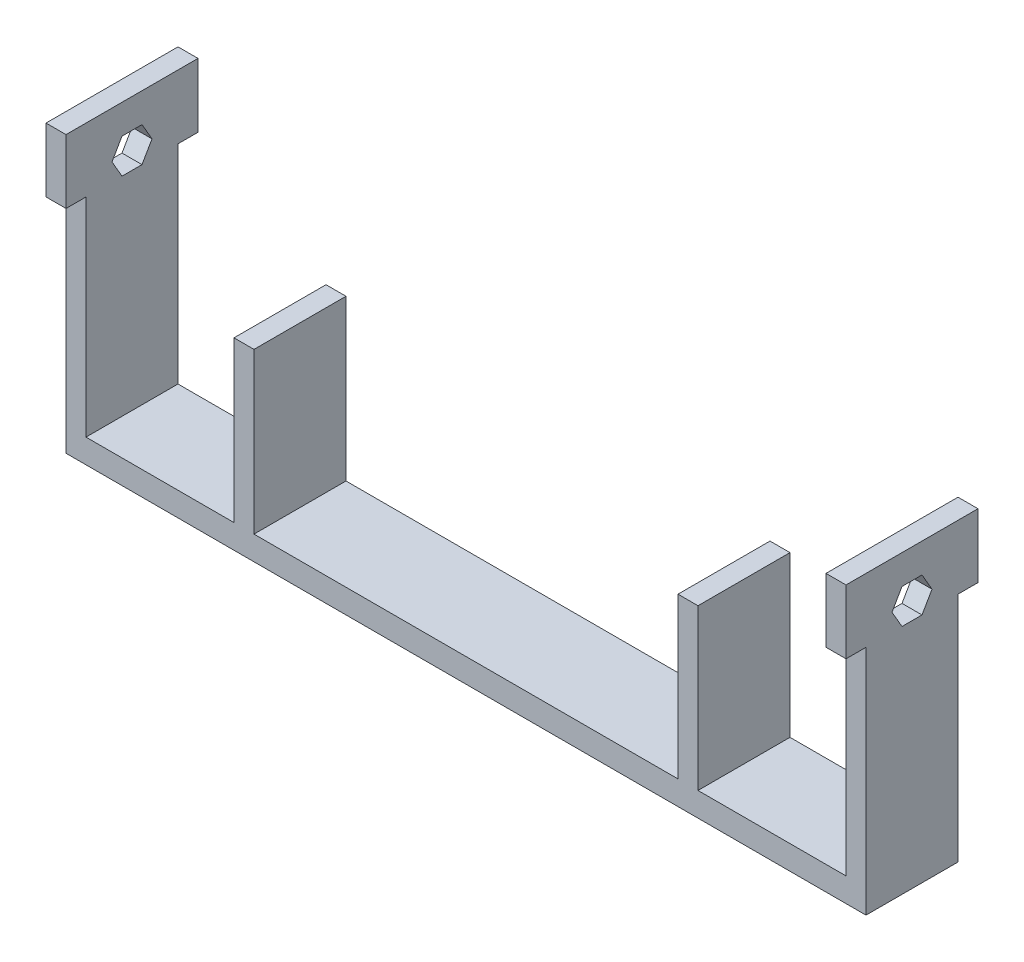
from build123d import *

# Parameters (mm, degrees)
SKETCH_1_W          = 100
SKETCH_1_H          = 11.5
EXTRUDE_1_DEPTH     = 3
SKETCH_2_W          = 2.5
SKETCH_2_H          = 11.5
EXTRUDE_2_DEPTH     = 26
SKETCH_3_W          = 2.5
SKETCH_3_H          = 11.5
EXTRUDE_3_DEPTH     = 20
SKETCH_6_W          = 2.5
SKETCH_6_H          = 16.5
EXTRUDE_4_DEPTH     = 8
CUT_EXTRUDE_1_DEPTH = 101


with BuildPart() as part:
    # 草图1 → 凸台-拉伸1 (new body)
    with BuildSketch(Plane(origin=(0, 0, 0), x_dir=(1, 0, 0), z_dir=(0, 1, 0))):
        with Locations((50, 5.75)):
            Rectangle(SKETCH_1_W, SKETCH_1_H)
    extrude(amount=EXTRUDE_1_DEPTH)

    # 草图2 → 凸台-拉伸2 (add)
    with BuildSketch(Plane(origin=(0, 3, 0), x_dir=(1, 0, 0), z_dir=(0, 1, 0))):
        with Locations((1.25, 5.75)):
            Rectangle(SKETCH_2_W, SKETCH_2_H)
        with Locations((98.75, 5.75)):
            Rectangle(SKETCH_2_W, SKETCH_2_H)
    extrude(amount=EXTRUDE_2_DEPTH)

    # 草图3 → 凸台-拉伸3 (add)
    with BuildSketch(Plane(origin=(0, 3, 0), x_dir=(1, 0, 0), z_dir=(0, 1, 0))):
        with Locations((22.25, 5.75)):
            Rectangle(SKETCH_3_W, SKETCH_3_H)
        with Locations((77.75, 5.75)):
            Rectangle(SKETCH_3_W, SKETCH_3_H)
    extrude(amount=EXTRUDE_3_DEPTH)

    # 草图6 → 凸台-拉伸4 (add)
    with BuildSketch(Plane(origin=(0, 29, 0), x_dir=(1, 0, 0), z_dir=(0, 1, 0))):
        with Locations((1.25, 5.75)):
            Rectangle(SKETCH_6_W, SKETCH_6_H)
        with Locations((98.75, 5.75)):
            Rectangle(SKETCH_6_W, SKETCH_6_H)
    extrude(amount=EXTRUDE_4_DEPTH)

    # 草图5 → 切除-拉伸1 (cut, through all)
    with BuildSketch(Plane(origin=(100, 0, 0), x_dir=(0, 0, -1), z_dir=(1, 0, 0))):
        Polygon((8.25, 31.165063509), (7, 33.330127019), (4.5, 33.330127019), (3.25, 31.165063509), (4.5, 29), (7, 29), align=None)
    extrude(amount=-CUT_EXTRUDE_1_DEPTH, mode=Mode.SUBTRACT)


solid = part.part
